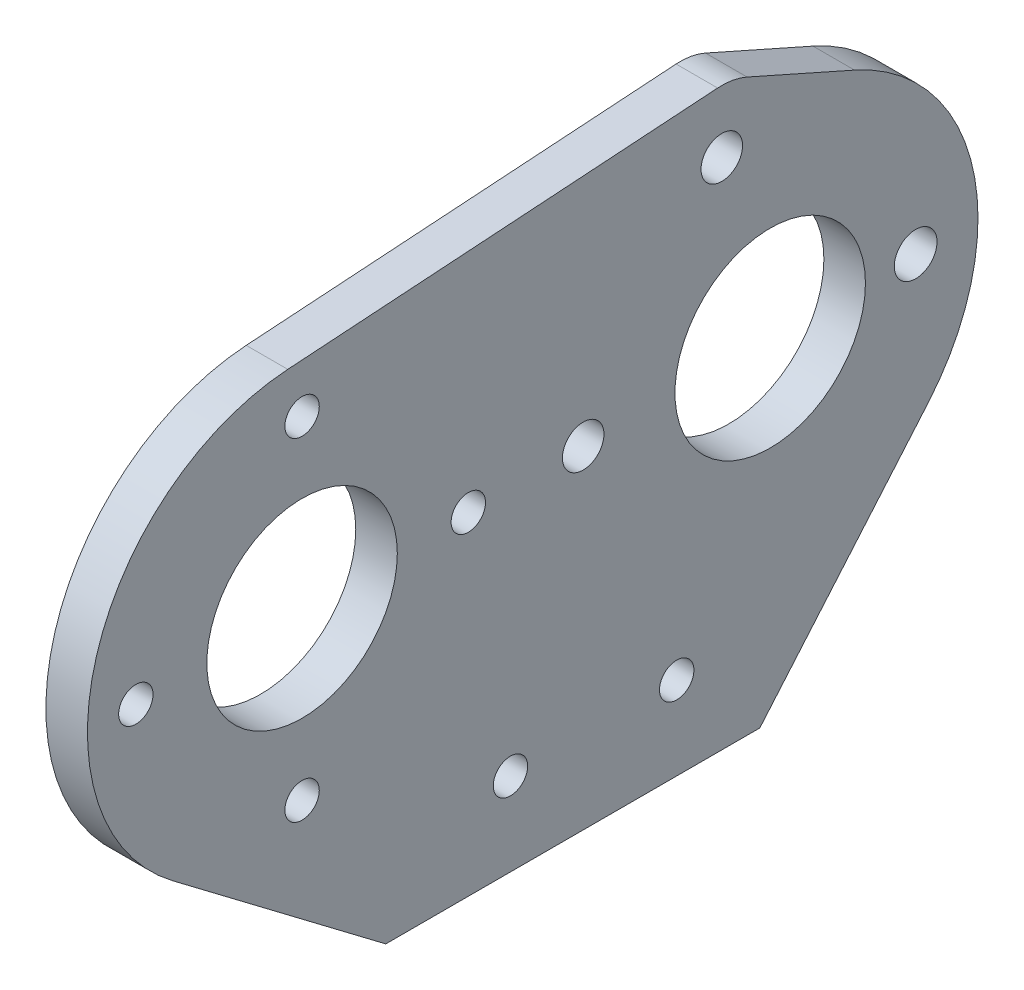
from build123d import *

# Parameters (mm, degrees)
SKETCH1_R           = 2.6289
SKETCH1_R_2         = 14.5542
SKETCH1_R_3         = 3.175
SKETCH1_R_4         = 3.2639
CORE_GEOMETRY_DEPTH = 6.35


with BuildPart() as part:
    # Sketch1 → Core geometry (new body)
    with BuildSketch(Plane(origin=(0, 0, 0), x_dir=(0, 0, -1), z_dir=(1, 0, 0))):
        with BuildLine():
            Line((76.2, 0), (101.94847561, 30.201219512))
            ThreePointArc((101.94847561, 30.201219512), (108.748010679, 57.836283003), (90.672243723, 79.818026797))
            Line((90.672243723, 79.818026797), (74.257168903, 87.106738525))
            ThreePointArc((74.257168903, 87.106738525), (72.055689407, 87.779865373), (69.757012949, 87.905158095))
            Line((69.757012949, 87.905158095), (4.07592642, 83.518510516))
            ThreePointArc((4.07592642, 83.518510516), (-25.155846577, 60.194220655), (-13.526294854, 24.651674645))
            Line((-13.526294854, 24.651674645), (19.05, 0))
            Line((19.05, 0), (76.2, 0))
        make_face()
        with Locations((38.1, 12.7)):
            Circle(SKETCH1_R, mode=Mode.SUBTRACT)
        with Locations((63.5, 12.7)):
            Circle(SKETCH1_R, mode=Mode.SUBTRACT)
        with Locations((77.7875, 50.8)):
            Circle(SKETCH1_R_2, mode=Mode.SUBTRACT)
        with Locations((6.2611, 50.8)):
            Circle(SKETCH1_R_2, mode=Mode.SUBTRACT)
        with Locations((6.2611, 76.2)):
            Circle(SKETCH1_R, mode=Mode.SUBTRACT)
        with Locations((6.2611, 25.4)):
            Circle(SKETCH1_R, mode=Mode.SUBTRACT)
        with Locations((31.6611, 50.8)):
            Circle(SKETCH1_R, mode=Mode.SUBTRACT)
        with Locations((-19.1389, 50.8)):
            Circle(SKETCH1_R, mode=Mode.SUBTRACT)
        with Locations((49.2125, 50.8)):
            Circle(SKETCH1_R_3, mode=Mode.SUBTRACT)
        with Locations((70.391745786, 78.401330486)):
            Circle(SKETCH1_R_3, mode=Mode.SUBTRACT)
        with Locations((100.0125, 50.8)):
            Circle(SKETCH1_R_4, mode=Mode.SUBTRACT)
    extrude(amount=CORE_GEOMETRY_DEPTH)


solid = part.part
